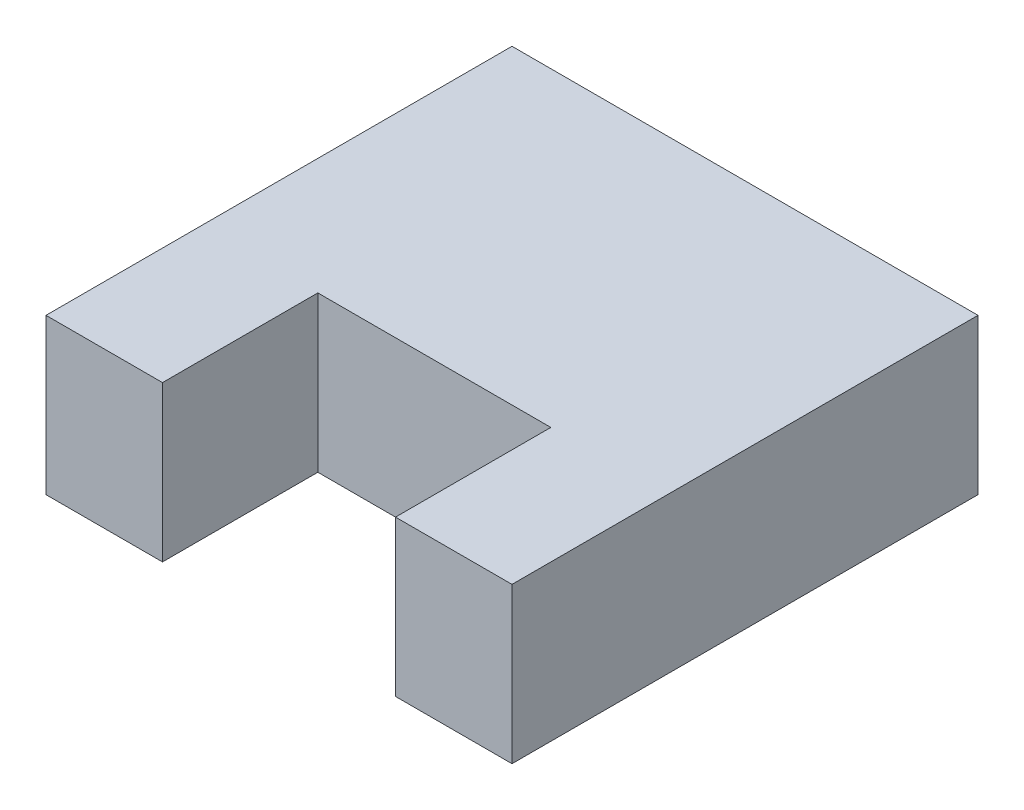
from build123d import *

# Parameters (mm, degrees)
BOSS_EXTRUDE1_DEPTH = 10


with BuildPart() as part:
    # Sketch1 → Boss-Extrude1 (new body, symmetric)
    with BuildSketch(Plane(origin=(0, 0, 0), x_dir=(1, 0, 0), z_dir=(0, 1, 0))):
        Polygon((0, 0), (60, 0), (60, -60), (45, -60), (45, -40), (15, -40), (15, -60), (0, -60), align=None)
    extrude(amount=BOSS_EXTRUDE1_DEPTH, both=True)


solid = part.part
